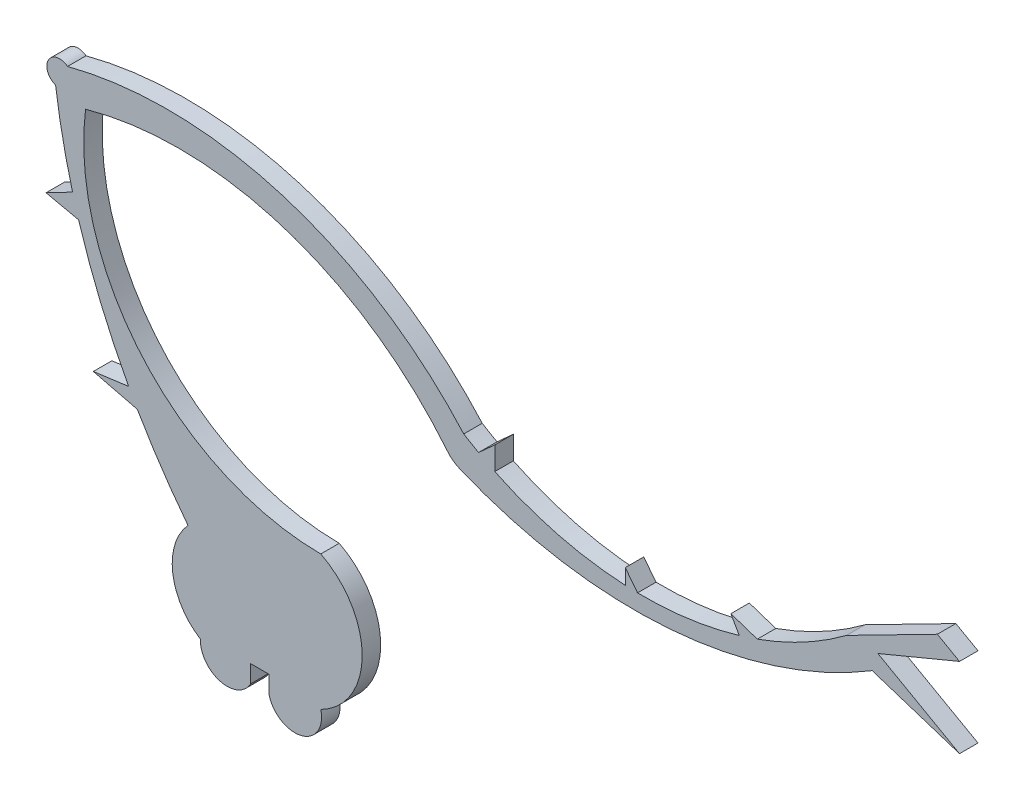
from build123d import *

# Parameters (mm, degrees)
BOSS_EXTRUDE1_DEPTH = 1.524


with BuildPart() as part:
    # Sketch1 → Boss-Extrude1 (new body)
    with BuildSketch(Plane.XY):
        with BuildLine():
            ThreePointArc((-16.197076151, 32.337475868), (-17.011067411, 35.784074673), (-17.596756232, 39.276723195))
            ThreePointArc((-17.596756232, 39.276723195), (-18.186455817, 40.773995588), (-16.610546214, 41.09969352))
            ThreePointArc((-16.610546214, 41.09969352), (1.114796248, 40.752315398), (16.047100727, 31.195395396))
            ThreePointArc((16.047100727, 31.195395396), (16.65383311, 30.831484379), (17.269539256, 30.482971317))
            Line((17.269539256, 30.482971317), (18.609894912, 31.696837019))
            Line((18.609894912, 31.696837019), (18.609894912, 29.792589361))
            ThreePointArc((18.609894912, 29.792589361), (23.848153012, 27.88417162), (29.360160247, 27.048000318))
            Line((29.360160247, 27.048000318), (29.360160247, 28.312908217))
            Line((29.360160247, 28.312908217), (30.371964085, 27.014480945))
            ThreePointArc((30.371964085, 27.014480945), (34.609173407, 27.271356348), (38.759272861, 28.163882163))
            Line((38.759272861, 28.163882163), (38.063395752, 29.375894853))
            Line((38.063395752, 29.375894853), (40.24389972, 28.648108402))
            ThreePointArc((40.24389972, 28.648108402), (44.068672668, 30.34536008), (47.598834428, 32.592026348))
            Line((47.598834428, 32.592026348), (55.083699621, 36.417717956))
            Line((55.083699621, 36.417717956), (56.910260303, 35.388944708))
            Line((56.910260303, 35.388944708), (50.185076604, 32.592026348))
            Line((50.185076604, 32.592026348), (56.910260303, 28.804203066))
            Line((56.910260303, 28.804203066), (49.712738856, 31.130827352))
            ThreePointArc((49.712738856, 31.130827352), (33.020763696, 25.765572392), (15.708965282, 28.542194647))
            ThreePointArc((15.708965282, 28.542194647), (15.163131597, 28.853301218), (14.710356917, 29.288866136))
            ThreePointArc((14.710356917, 29.288866136), (1.215411603, 38.505400506), (-15.123980563, 38.792312441))
            ThreePointArc((-15.123980563, 38.792312441), (-10.396030461, 23.399793439), (4.263099046, 16.736980561))
            ThreePointArc((4.263099046, 16.736980561), (7.676752936, 11.186831392), (4.263099046, 5.636682223))
            ThreePointArc((4.263099046, 5.636682223), (2.666546478, 2.970135745), (0, 4.566688313))
            Line((0, 4.566688313), (0, 6.017862143))
            Line((0, 6.017862143), (-1.524, 6.017862143))
            Line((-1.524, 6.017862143), (-1.524, 4.566688313))
            ThreePointArc((-1.524, 4.566688313), (-4.040524665, 3.505966865), (-5.665097739, 5.701140823))
            ThreePointArc((-5.665097739, 5.701140823), (-7.938147597, 9.268051635), (-6.680633826, 13.306401238))
            ThreePointArc((-6.680633826, 13.306401238), (-8.875864768, 16.330833019), (-10.856041848, 19.50023757))
            Line((-10.856041848, 19.50023757), (-14.485790124, 20.389849107))
            Line((-14.485790124, 20.389849107), (-11.572605425, 20.780961266))
            ThreePointArc((-11.572605425, 20.780961266), (-13.878489207, 25.592275915), (-15.696943684, 30.608157889))
            Line((-15.696943684, 30.608157889), (-18.384655546, 31.195395396))
            Line((-18.384655546, 31.195395396), (-16.197076151, 32.337475868))
        make_face()
    extrude(amount=BOSS_EXTRUDE1_DEPTH)


solid = part.part
